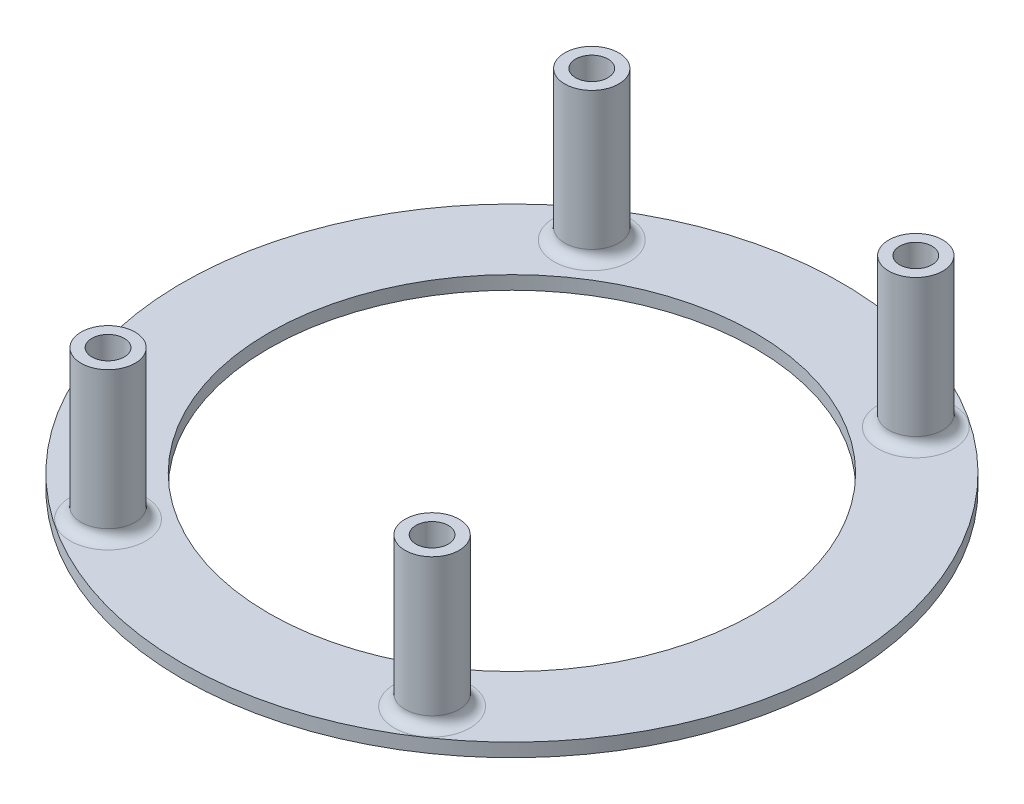
from build123d import *

# Parameters (mm, degrees)
SKETCH2_R             = 6.35
SKETCH2_R_2           = 3.81
BOSS_EXTRUDE1_DEPTH   = 34.925
BOSS_EXTRUDE1_2_DEPTH = 34.925
BOSS_EXTRUDE1_3_DEPTH = 34.925
BOSS_EXTRUDE1_4_DEPTH = 34.925
SKETCH1_R             = 77.4954
SKETCH1_R_2           = 57.15
BOSS_EXTRUDE2_DEPTH   = 3.175
SKETCH3_R             = 3.81
CUT_EXTRUDE1_DEPTH    = 4.175
FILLET1_R             = 2.54


with BuildPart() as part:
    # Sketch2 → Boss-Extrude1 (new body)
    with BuildSketch(Plane(origin=(0, -40.33266, 0), x_dir=(1, 0, 0), z_dir=(0, 1, 0))):
        with Locations((-38.1, 56.870055469)):
            Circle(SKETCH2_R)
        with Locations((-38.1, 56.870055469)):
            Circle(SKETCH2_R_2, mode=Mode.SUBTRACT)
    extrude(amount=BOSS_EXTRUDE1_DEPTH)



with BuildPart() as body_2:
    # Sketch2 → Boss-Extrude1 2 (new body)
    with BuildSketch(Plane(origin=(0, -40.33266, 0), x_dir=(1, 0, 0), z_dir=(0, 1, 0))):
        with Locations((38.1, 56.870055469)):
            Circle(SKETCH2_R)
        with Locations((38.1, 56.870055469)):
            Circle(SKETCH2_R_2, mode=Mode.SUBTRACT)
    extrude(amount=BOSS_EXTRUDE1_2_DEPTH)


with BuildPart() as body_3:
    # Sketch2 → Boss-Extrude1 3 (new body)
    with BuildSketch(Plane(origin=(0, -40.33266, 0), x_dir=(1, 0, 0), z_dir=(0, 1, 0))):
        with Locations((38.1, -56.870055469)):
            Circle(SKETCH2_R)
        with Locations((38.1, -56.870055469)):
            Circle(SKETCH2_R_2, mode=Mode.SUBTRACT)
    extrude(amount=BOSS_EXTRUDE1_3_DEPTH)


with BuildPart() as body_4:
    # Sketch2 → Boss-Extrude1 4 (new body)
    with BuildSketch(Plane(origin=(0, -40.33266, 0), x_dir=(1, 0, 0), z_dir=(0, 1, 0))):
        with Locations((-38.1, -56.870055469)):
            Circle(SKETCH2_R)
        with Locations((-38.1, -56.870055469)):
            Circle(SKETCH2_R_2, mode=Mode.SUBTRACT)
    extrude(amount=BOSS_EXTRUDE1_4_DEPTH)


with BuildPart() as part_1:
    add(part.part)

    add(body_2.part)  # Boss-Extrude2 merges body 2

    add(body_3.part)  # Boss-Extrude2 merges body 3

    add(body_4.part)  # Boss-Extrude2 merges body 4
    # Sketch1 → Boss-Extrude2 (add)
    with BuildSketch(Plane(origin=(0, -40.33266, 0), x_dir=(1, 0, 0), z_dir=(0, 1, 0))):
        Circle(SKETCH1_R)
        Circle(SKETCH1_R_2, mode=Mode.SUBTRACT)
    extrude(amount=-BOSS_EXTRUDE2_DEPTH)

    # Sketch3 → Cut-Extrude1 (cut, through all)
    with BuildSketch(Plane(origin=(0, -40.33266, 0), x_dir=(1, 0, 0), z_dir=(0, 1, 0))):
        with Locations((-38.1, -56.870055469)):
            Circle(SKETCH3_R)
        with Locations((38.1, -56.870055469)):
            Circle(SKETCH3_R)
        with Locations((38.1, 56.870055469)):
            Circle(SKETCH3_R)
        with Locations((-38.1, 56.870055469)):
            Circle(SKETCH3_R)
    extrude(amount=-CUT_EXTRUDE1_DEPTH, mode=Mode.SUBTRACT)

    # Fillet1
    fillet1_edges = [part_1.edges().sort_by_distance(p)[0] for p in [
        (-44.45, -40.33266, -56.870055469),
        (31.75, -40.33266, -56.870055469),
        (31.75, -40.33266, 56.870055469),
        (-44.45, -40.33266, 56.870055469),
    ]]
    fillet(fillet1_edges, radius=FILLET1_R)


solid = part_1.part
